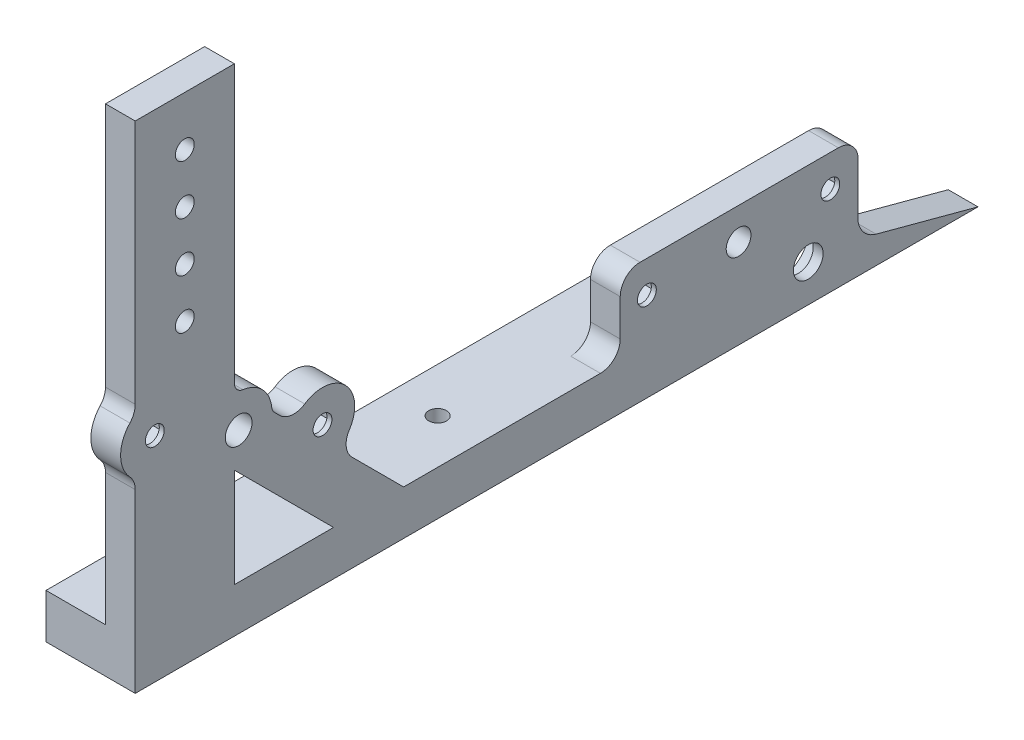
from build123d import *

# Parameters (mm, degrees)
SKETCH1_R           = 7.9375
SKETCH1_R_2         = 2.413
SKETCH1_R_3         = 3.175
SKETCH1_R_4         = 3.429
BOSS_EXTRUDE1_DEPTH = 7.62
SKETCH2_R           = 7.9375
SKETCH2_R_2         = 3.81
BOSS_EXTRUDE2_DEPTH = 2.54
SKETCH3_W           = 154.94
SKETCH3_H           = 11.43
BOSS_EXTRUDE3_DEPTH = 15.24
FILLET1_R           = 5.08
SKETCH5_R           = 2.286
CUT_EXTRUDE1_DEPTH  = 128
CUT_EXTRUDE2_DEPTH  = 6.35
CUT_EXTRUDE3_DEPTH  = 6.35


with BuildPart() as part:
    # Sketch1 → Boss-Extrude1 (new body)
    with BuildSketch(Plane(origin=(0, 0, 0), x_dir=(0, 0, -1), z_dir=(1, 0, 0))):
        with BuildLine():
            Line((0, 0), (127, 0))
            Line((127, 0), (100.900837488, 6.993249518))
            ThreePointArc((100.900837488, 6.993249518), (97.889599245, 8.807630529), (96.305117976, 11.94593474))
            Line((96.305117976, 11.94593474), (96.305117976, 25.91593474))
            ThreePointArc((96.305117976, 25.91593474), (94.817220425, 29.508037188), (91.225117976, 30.99593474))
            Line((91.225117976, 30.99593474), (40.425117976, 30.99593474))
            ThreePointArc((40.425117976, 30.99593474), (36.833015528, 29.508037188), (35.345117976, 25.91593474))
            Line((35.345117976, 25.91593474), (35.345117976, 16.51))
            ThreePointArc((35.345117976, 16.51), (33.857220425, 12.917897552), (30.265117976, 11.43))
            Line((30.265117976, 11.43), (0, 11.43))
            Line((0, 11.43), (-20.139487758, 11.43))
            Line((-20.139487758, 11.43), (-33.393348427, 24.683860669))
            ThreePointArc((-33.393348427, 24.683860669), (-34.855521636, 27.76537759), (-34.039193709, 31.077069869))
            ThreePointArc((-34.039193709, 31.077069869), (-35.088692293, 41.466034818), (-45.477657242, 42.515533402))
            ThreePointArc((-45.477657242, 42.515533402), (-48.789349521, 41.699205475), (-51.870866442, 43.161378684))
            Line((-51.870866442, 43.161378684), (-53.208352597, 44.49886484))
            ThreePointArc((-53.208352597, 44.49886484), (-53.705674947, 45.203111295), (-53.938776392, 46.033145213))
            ThreePointArc((-53.938776392, 46.033145213), (-56.302994281, 51.089129932), (-61.291601771, 53.592388411))
            ThreePointArc((-61.291601771, 53.592388411), (-62.869694805, 54.435936137), (-63.5, 56.110649769))
            Line((-63.5, 56.110649769), (-63.5, 127))
            Line((-63.5, 127), (-88.9, 127))
            Line((-88.9, 127), (-88.9, 64.149284844))
            ThreePointArc((-88.9, 64.149284844), (-89.255767512, 62.281658704), (-90.273239134, 60.675623392))
            ThreePointArc((-90.273239134, 60.675623392), (-92.64207664, 54.683557387), (-90.273239134, 48.691491383))
            ThreePointArc((-90.273239134, 48.691491383), (-89.255767512, 47.085456071), (-88.9, 45.217829931))
            Line((-88.9, 45.217829931), (-88.9, 0))
            Line((-88.9, 0), (0, 0))
        make_face()
        with Locations((83.514716058, 9.525)):
            Circle(SKETCH1_R, mode=Mode.SUBTRACT)
        with Locations((-76.2, 114.3)):
            Circle(SKETCH1_R_2, mode=Mode.SUBTRACT)
        with Locations((-76.2, 88.9)):
            Circle(SKETCH1_R_2, mode=Mode.SUBTRACT)
        with Locations((-76.2, 101.6)):
            Circle(SKETCH1_R_2, mode=Mode.SUBTRACT)
        with Locations((-76.2, 76.2)):
            Circle(SKETCH1_R_2, mode=Mode.SUBTRACT)
        with Locations((65.671256734, 22.86)):
            Circle(SKETCH1_R_3, mode=Mode.SUBTRACT)
        with Locations((-62.402467706, 45.156212864)):
            Circle(SKETCH1_R_4, mode=Mode.SUBTRACT)
        with Locations((42.176256734, 22.86)):
            Circle(SKETCH1_R_2, mode=Mode.SUBTRACT)
        with Locations((89.166256734, 22.86)):
            Circle(SKETCH1_R_2, mode=Mode.SUBTRACT)
        with Locations((-83.87907664, 54.683557387)):
            Circle(SKETCH1_R_2, mode=Mode.SUBTRACT)
        with Locations((-40.925858771, 35.62886834)):
            Circle(SKETCH1_R_2, mode=Mode.SUBTRACT)
        Polygon((-63.5, 11.43), (-63.5, 36.83), (-38.1, 11.43), align=None, mode=Mode.SUBTRACT)
    extrude(amount=BOSS_EXTRUDE1_DEPTH)

    # Sketch2 → Boss-Extrude2 (add)
    with BuildSketch(Plane(origin=(7.62, 0, 0), x_dir=(0, 0, -1), z_dir=(1, 0, 0))):
        with Locations((83.514716058, 9.525)):
            Circle(SKETCH2_R)
        with Locations((83.514716058, 9.525)):
            Circle(SKETCH2_R_2, mode=Mode.SUBTRACT)
    extrude(amount=-BOSS_EXTRUDE2_DEPTH)

    # Sketch3 → Boss-Extrude3 (add)
    with BuildSketch(Plane.ZY):
        with Locations((11.43, 5.715)):
            Rectangle(SKETCH3_W, SKETCH3_H)
    extrude(amount=BOSS_EXTRUDE3_DEPTH)

    # Fillet1
    fillet1_edges = [part.edges().sort_by_distance(p)[0] for p in [
        (0, 5.715, -66.04),
    ]]
    fillet(fillet1_edges, radius=FILLET1_R)

    # Sketch5 → Cut-Extrude1 (cut, through all)
    with BuildSketch(Plane.XZ):
        with Locations((-3.81, -50.8)):
            Circle(SKETCH5_R)
        with Locations((-3.81, 0)):
            Circle(SKETCH5_R)
    extrude(amount=-CUT_EXTRUDE1_DEPTH, mode=Mode.SUBTRACT)

    # Sketch6 → Cut-Extrude2 (cut)
    with BuildSketch(Plane.XZ):
        Polygon((1.61593783, -50.8), (-1.097031085, -46.101), (-6.522968915, -46.101), (-9.23593783, -50.8), (-6.522968915, -55.499), (-1.097031085, -55.499), align=None)
        Polygon((-1.097031085, -4.699), (1.61593783, 0), (-1.097031085, 4.699), (-6.522968915, 4.699), (-9.23593783, 0), (-6.522968915, -4.699), align=None)
    extrude(amount=-CUT_EXTRUDE2_DEPTH, mode=Mode.SUBTRACT)

    # Sketch7 → Cut-Extrude3 (cut)
    with BuildSketch(Plane.ZY):
        Polygon((-84.467256734, 25.572968915), (-89.166256734, 28.28593783), (-93.865256734, 25.572968915), (-93.865256734, 20.147031085), (-89.166256734, 17.43406217), (-84.467256734, 20.147031085), align=None)
        Polygon((-37.477256734, 25.572968915), (-42.176256734, 28.28593783), (-46.875256734, 25.572968915), (-46.875256734, 20.147031085), (-42.176256734, 17.43406217), (-37.477256734, 20.147031085), align=None)
        Polygon((45.624858771, 38.341837255), (40.925858771, 41.054806169), (36.226858771, 38.341837255), (36.226858771, 32.915899425), (40.925858771, 30.20293051), (45.624858771, 32.915899425), align=None)
        Polygon((88.57807664, 57.396526302), (83.87907664, 60.109495217), (79.18007664, 57.396526302), (79.18007664, 51.970588472), (83.87907664, 49.257619558), (88.57807664, 51.970588472), align=None)
    extrude(amount=-CUT_EXTRUDE3_DEPTH, mode=Mode.SUBTRACT)


solid = part.part
